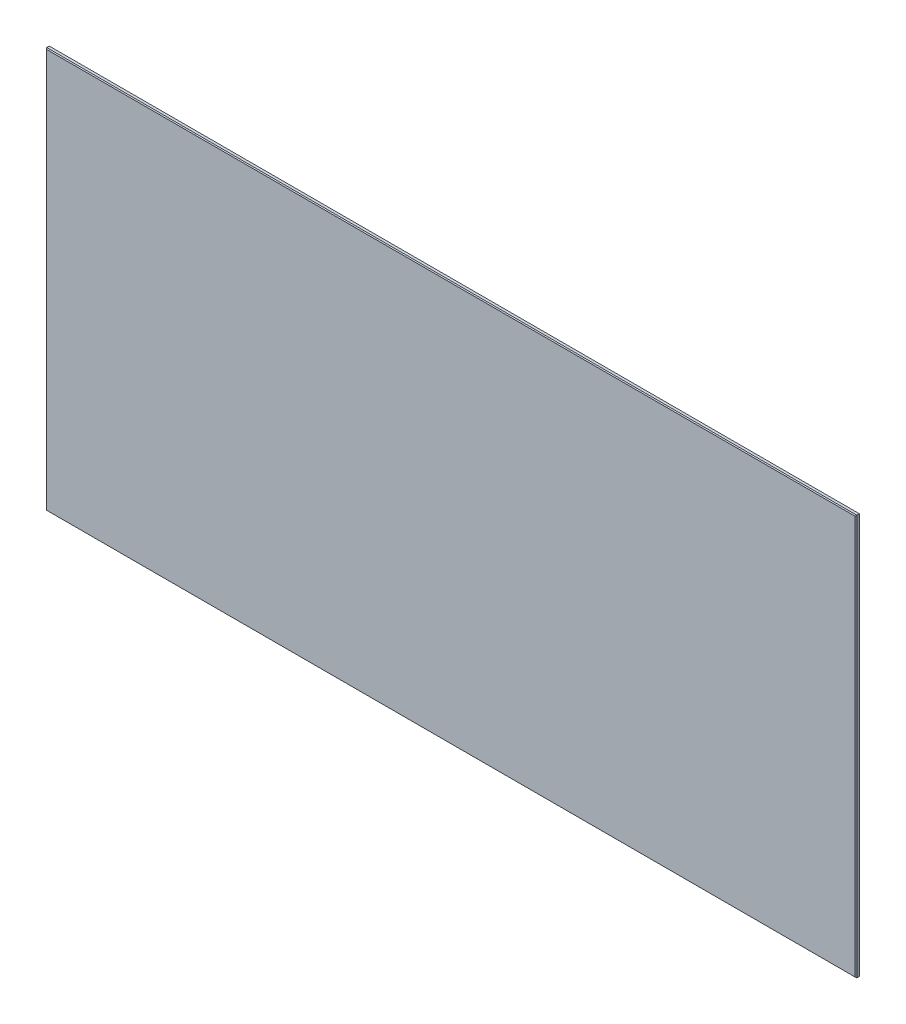
from build123d import *

# Parameters (mm, degrees)
BOSS_EXTRUDE1_DEPTH      = 603.25
BOSS_EXTRUDE1_DEPTH_BACK = 603.25
CHAMFER1_SIZE            = 1.27


with BuildPart() as part:
    # Sketch1 → Boss-Extrude1 (new body, two sides)
    with BuildSketch(Plane(origin=(0, 0, 0), x_dir=(0, 0, -1), z_dir=(1, 0, 0))) as boss_extrude1_sk:
        Polygon((3.175, -297.18), (3.175, 297.18), (1.905, 298.45), (-1.905, 298.45), (-3.175, 297.18), (-3.175, -297.18), (-1.905, -298.45), (1.905, -298.45), align=None)
    extrude(amount=BOSS_EXTRUDE1_DEPTH)
    extrude(boss_extrude1_sk.sketch, amount=-BOSS_EXTRUDE1_DEPTH_BACK)

    # Chamfer1
    chamfer1_edges = [part.edges().sort_by_distance(p)[0] for p in [
        (-603.25, 0, -3.175),
        (-603.25, 0, 3.175),
        (603.25, 0, -3.175),
        (603.25, 0, 3.175),
    ]]
    chamfer(chamfer1_edges, length=CHAMFER1_SIZE)


solid = part.part
